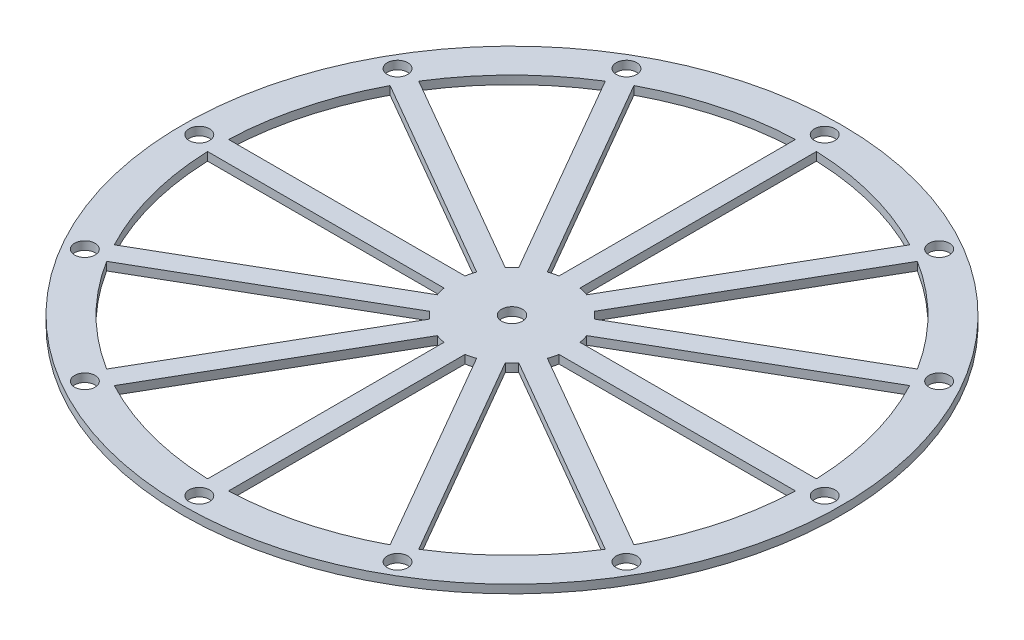
from build123d import *

# Parameters (mm, degrees)
SKETCH1_R            = 474.432327188
SKETCH1_R_2          = 15
SKETCH1_R_3          = 14.738282491
BOSS_EXTRUDE15_DEPTH = 12


with BuildPart() as part:
    # Sketch1 → Boss-Extrude15 (new body)
    with BuildSketch(Plane(origin=(0, 0, 0), x_dir=(1, 0, 0), z_dir=(0, 1, 0))):
        Circle(SKETCH1_R)
        Circle(SKETCH1_R_2, mode=Mode.SUBTRACT)
        with Locations((0, 450.168808025)):
            Circle(SKETCH1_R_3, mode=Mode.SUBTRACT)
        with Locations((225.084404013, 389.857623741)):
            Circle(SKETCH1_R_3, mode=Mode.SUBTRACT)
        with Locations((389.857623741, 225.084404013)):
            Circle(SKETCH1_R_3, mode=Mode.SUBTRACT)
        with Locations((450.168808025, 0)):
            Circle(SKETCH1_R_3, mode=Mode.SUBTRACT)
        with Locations((389.857623741, -225.084404013)):
            Circle(SKETCH1_R_3, mode=Mode.SUBTRACT)
        with Locations((225.084404013, -389.857623741)):
            Circle(SKETCH1_R_3, mode=Mode.SUBTRACT)
        with Locations((0, -450.168808025)):
            Circle(SKETCH1_R_3, mode=Mode.SUBTRACT)
        with Locations((-225.084404012, -389.857623741)):
            Circle(SKETCH1_R_3, mode=Mode.SUBTRACT)
        with Locations((-389.857623741, -225.084404013)):
            Circle(SKETCH1_R_3, mode=Mode.SUBTRACT)
        with Locations((-450.168808025, 0)):
            Circle(SKETCH1_R_3, mode=Mode.SUBTRACT)
        with Locations((-389.857623741, 225.084404013)):
            Circle(SKETCH1_R_3, mode=Mode.SUBTRACT)
        with Locations((-225.084404013, 389.857623741)):
            Circle(SKETCH1_R_3, mode=Mode.SUBTRACT)
        with BuildLine():
            Line((15.084021598, 423.182152072), (15.084021598, 82.782783758))
            ThreePointArc((15.084021598, 82.782783758), (21.778537661, 81.278609065), (28.328245984, 79.234004529))
            Line((28.328245984, 79.234004529), (198.527930141, 374.028504921))
            ThreePointArc((198.527930141, 374.028504921), (109.597156617, 409.022156859), (15.084021598, 423.182152072))
        make_face(mode=Mode.SUBTRACT)
        with BuildLine():
            Line((-15.084021598, 423.182152072), (-15.084021598, 82.782783758))
            ThreePointArc((-15.084021598, 82.782783758), (-21.778537661, 81.278609065), (-28.328245984, 79.234004529))
            Line((-28.328245984, 79.234004529), (-198.527930141, 374.028504921))
            ThreePointArc((-198.527930141, 374.028504921), (-109.597156617, 409.022156859), (-15.084021598, 423.182152072))
        make_face(mode=Mode.SUBTRACT)
        with BuildLine():
            Line((224.654221931, 358.944483323), (54.454537774, 64.149982931))
            ThreePointArc((54.454537774, 64.149982931), (59.500071404, 59.500071404), (64.149982931, 54.454537774))
            Line((64.149982931, 54.454537774), (358.944483323, 224.654221931))
            ThreePointArc((358.944483323, 224.654221931), (299.425000242, 299.425000242), (224.654221931, 358.944483323))
        make_face(mode=Mode.SUBTRACT)
        with BuildLine():
            Line((374.028504921, 198.527930141), (79.234004529, 28.328245984))
            ThreePointArc((79.234004529, 28.328245984), (81.278609065, 21.778537661), (82.782783758, 15.084021598))
            Line((82.782783758, 15.084021598), (423.182152072, 15.084021598))
            ThreePointArc((423.182152072, 15.084021598), (409.022156859, 109.597156617), (374.028504921, 198.527930141))
        make_face(mode=Mode.SUBTRACT)
        with BuildLine():
            Line((423.182152072, -15.084021598), (82.782783758, -15.084021598))
            ThreePointArc((82.782783758, -15.084021598), (81.278609065, -21.778537661), (79.234004529, -28.328245984))
            Line((79.234004529, -28.328245984), (374.028504921, -198.527930141))
            ThreePointArc((374.028504921, -198.527930141), (409.022156859, -109.597156617), (423.182152072, -15.084021598))
        make_face(mode=Mode.SUBTRACT)
        with BuildLine():
            Line((358.944483323, -224.654221931), (64.149982931, -54.454537774))
            ThreePointArc((64.149982931, -54.454537774), (59.500071404, -59.500071404), (54.454537774, -64.149982931))
            Line((54.454537774, -64.149982931), (224.654221931, -358.944483323))
            ThreePointArc((224.654221931, -358.944483323), (299.425000242, -299.425000242), (358.944483323, -224.654221931))
        make_face(mode=Mode.SUBTRACT)
        with BuildLine():
            Line((198.527930141, -374.028504921), (28.328245984, -79.234004529))
            ThreePointArc((28.328245984, -79.234004529), (21.778537661, -81.278609065), (15.084021598, -82.782783758))
            Line((15.084021598, -82.782783758), (15.084021598, -423.182152072))
            ThreePointArc((15.084021598, -423.182152072), (109.597156617, -409.022156859), (198.527930141, -374.028504921))
        make_face(mode=Mode.SUBTRACT)
        with BuildLine():
            Line((-15.084021598, -423.182152072), (-15.084021598, -82.782783758))
            ThreePointArc((-15.084021598, -82.782783758), (-21.778537661, -81.278609065), (-28.328245984, -79.234004529))
            Line((-28.328245984, -79.234004529), (-198.527930141, -374.028504921))
            ThreePointArc((-198.527930141, -374.028504921), (-109.597156617, -409.022156859), (-15.084021598, -423.182152072))
        make_face(mode=Mode.SUBTRACT)
        with BuildLine():
            Line((-224.654221931, -358.944483323), (-54.454537774, -64.149982931))
            ThreePointArc((-54.454537774, -64.149982931), (-59.500071404, -59.500071404), (-64.149982931, -54.454537774))
            Line((-64.149982931, -54.454537774), (-358.944483323, -224.654221931))
            ThreePointArc((-358.944483323, -224.654221931), (-299.425000242, -299.425000242), (-224.654221931, -358.944483323))
        make_face(mode=Mode.SUBTRACT)
        with BuildLine():
            Line((-374.028504921, -198.527930141), (-79.234004529, -28.328245984))
            ThreePointArc((-79.234004529, -28.328245984), (-81.278609065, -21.778537661), (-82.782783758, -15.084021598))
            Line((-82.782783758, -15.084021598), (-423.182152072, -15.084021598))
            ThreePointArc((-423.182152072, -15.084021598), (-409.022156859, -109.597156617), (-374.028504921, -198.527930141))
        make_face(mode=Mode.SUBTRACT)
        with BuildLine():
            Line((-423.182152072, 15.084021598), (-82.782783758, 15.084021598))
            ThreePointArc((-82.782783758, 15.084021598), (-81.278609065, 21.778537661), (-79.234004529, 28.328245984))
            Line((-79.234004529, 28.328245984), (-374.028504921, 198.527930141))
            ThreePointArc((-374.028504921, 198.527930141), (-409.022156859, 109.597156617), (-423.182152072, 15.084021598))
        make_face(mode=Mode.SUBTRACT)
        with BuildLine():
            Line((-358.944483323, 224.654221931), (-64.149982931, 54.454537774))
            ThreePointArc((-64.149982931, 54.454537774), (-59.500071404, 59.500071404), (-54.454537774, 64.149982931))
            Line((-54.454537774, 64.149982931), (-224.654221931, 358.944483323))
            ThreePointArc((-224.654221931, 358.944483323), (-299.425000242, 299.425000242), (-358.944483323, 224.654221931))
        make_face(mode=Mode.SUBTRACT)
    extrude(amount=BOSS_EXTRUDE15_DEPTH)


solid = part.part
